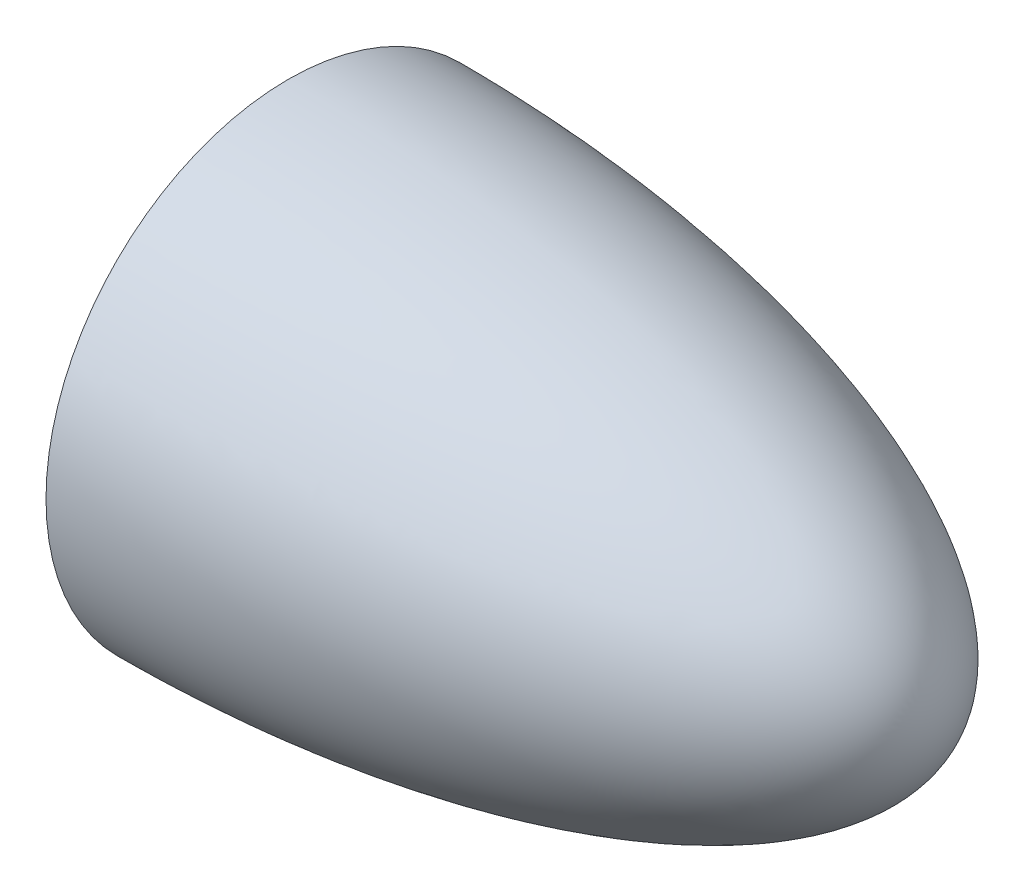
from build123d import *


with BuildPart() as part:
    # Sketch1 → Revolve2 (revolve)
    with BuildSketch(Plane.XY):
        with BuildLine():
            Line((-1e-09, 38.100000001), (-1e-09, 31.75))
            add(Edge.make_bspline(
                [(-1e-09, 31.75), (0.415190955, 31.75), (1.256679449, 31.748089378), (2.554706175, 31.740924525), (3.825770905, 31.725155281), (4.981143672, 31.707226625), (5.881733678, 31.690007829), (7.012498695, 31.664884491), (8.369799081, 31.628967402), (9.952482494, 31.578627475), (11.761183375, 31.509472003), (13.569243129, 31.428627236), (15.376822449, 31.336016415), (17.183708972, 31.231550801), (18.989890262, 31.115129308), (21.246578438, 30.954515104), (24.854866644, 30.665006375), (28.908660977, 30.274157416), (33.403796106, 29.753737054), (37.887250625, 29.142309392), (42.360436198, 28.459737481), (47.70908357, 27.521366996), (53.027668499, 26.421880543), (58.304789295, 25.138939788), (63.53814241, 23.689870329), (68.718734965, 22.058783783), (73.83193168, 20.156435427), (78.805751313, 17.912687574), (82.807503611, 15.748844266), (85.634582067, 13.964943786), (88.04379784, 12.17620139), (89.954295611, 10.49127296), (91.378434074, 9.012915483), (92.515776239, 7.603520907), (93.371759618, 6.327051803), (94.037101188, 5.108168569), (94.531894719, 3.958323968), (94.886900285, 2.857827481), (95.133086869, 1.729400952), (95.227625158, 0.883817947), (95.24997491, 0.309070901), (95.249999995, -1.2e-08)],
                knots=[0.082403978, 0.082403978, 0.082403978, 0.082403978, 0.082403978, 0.09805918, 0.113714381, 0.121541982, 0.129369583, 0.137197184, 0.145024784, 0.160679986, 0.176335188, 0.191990389, 0.207645591, 0.223300793, 0.238955994, 0.254611196, 0.270266398, 0.3015768, 0.364197607, 0.39550801, 0.426818411, 0.458128811, 0.520749617, 0.58337042, 0.614680825, 0.645991229, 0.708612011, 0.771232792, 0.803294465, 0.834604942, 0.865915313, 0.886788421, 0.906994607, 0.922648235, 0.936849643, 0.94937169, 0.960097506, 0.970627029, 0.980098404, 0.989316126, 1, 1, 1, 1, 1], degree=4))
            Line((95.249999995, -1.2e-08), (101.599999994, -1.2e-08))
            add(Edge.make_bspline(
                [(-1e-09, 38.100000001), (0.450260093, 38.100000001), (1.332272986, 38.097637889), (3.062345193, 38.087008359), (4.839563793, 38.058650103), (7.385317487, 38.005438149), (10.256702575, 37.913083534), (13.240315722, 37.784908905), (16.147697021, 37.620519144), (18.605854612, 37.459115574), (20.552882974, 37.31522258), (22.998301968, 37.116721594), (25.922930437, 36.848395016), (29.335173151, 36.490667744), (33.225015649, 36.018900169), (37.107938692, 35.48221487), (40.980119598, 34.878255234), (44.841253924, 34.204254741), (48.688602724, 33.456939061), (53.478286526, 32.426376782), (59.18886894, 31.026335536), (64.841399437, 29.402206908), (70.41170974, 27.51646904), (75.668754065, 25.475692998), (79.930197447, 23.588996516), (84.081947107, 21.467700997), (88.073614342, 19.060703593), (91.061868476, 16.969641497), (93.629746549, 14.863633228), (95.711452303, 12.845875297), (97.298665837, 11.033645771), (98.566232567, 9.306214415), (99.541973356, 7.697686694), (100.331861268, 6.088970168), (100.93817171, 4.472589012), (101.380823499, 2.757157275), (101.559164098, 1.388962916), (101.59998036, 0.483233633), (101.599999994, -1.2e-08)],
                knots=[0.080893284, 0.080893284, 0.080893284, 0.080893284, 0.080893284, 0.096491462, 0.112089641, 0.12768782, 0.143285999, 0.174482356, 0.205678713, 0.221276893, 0.236875072, 0.252473251, 0.268071431, 0.299267787, 0.330464142, 0.361660499, 0.392856856, 0.424053216, 0.455249576, 0.486445934, 0.517642292, 0.580034994, 0.642427695, 0.673624058, 0.704820421, 0.759551633, 0.790747942, 0.821944301, 0.853140636, 0.875573354, 0.89637091, 0.914156338, 0.92975217, 0.943709836, 0.956194275, 0.971146567, 0.984621316, 1, 1, 1, 1, 1], degree=4))
        make_face()
    revolve(axis=Axis((95.249999995, -1.2e-08, 0), (1, 0, 0)))


solid = part.part
